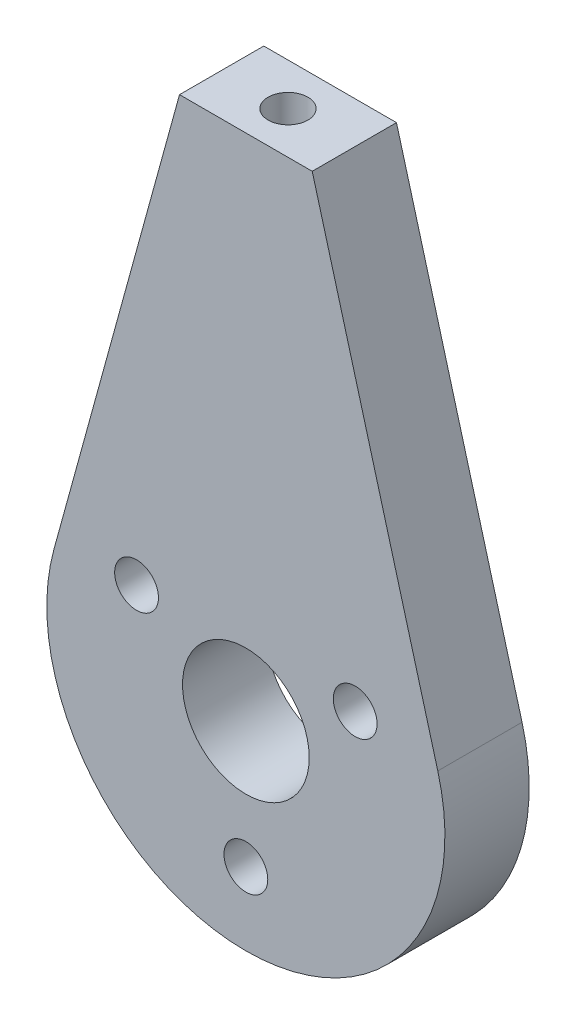
from build123d import *

# Parameters (mm, degrees)
BASE_DEPTH           = 3.175
BOSS_EXTRUDE1_DEPTH  = 6.35
SKETCH2_R            = 4.77266
SHAFT_AND_BOLT_DEPTH = 7.35
SKETCH5_R            = 1.5
CUT_EXTRUDE1_DEPTH   = 14
SKETCH6_R            = 1.65
CUT_EXTRUDE2_DEPTH   = 7.35


with BuildPart() as part:
    # Sketch1 → Base (new body, symmetric)
    with BuildSketch(Plane.XY):
        with BuildLine():
            Line((-5, 38.38), (-14.46282813, 3.978266268))
            ThreePointArc((-14.46282813, 3.978266268), (-14.389347628, -4.236351595), (-10, -11.180339887))
            Line((-10, -11.180339887), (10, -11.180339887))
            ThreePointArc((10, -11.180339887), (14.389347628, -4.236351595), (14.46282813, 3.978266268))
            Line((14.46282813, 3.978266268), (5, 38.38))
            Line((5, 38.38), (-5, 38.38))
        make_face()
    extrude(amount=BASE_DEPTH, both=True)

    # Sketch7 → Boss-Extrude1 (add)
    with BuildSketch(Plane.XY.offset(3.175)):
        with BuildLine():
            Line((-10, -11.180339887), (10, -11.180339887))
            ThreePointArc((10, -11.180339887), (0, -15), (-10, -11.180339887))
        make_face()
    extrude(amount=-BOSS_EXTRUDE1_DEPTH)

    # Sketch2 → Shaft and Bolt (cut, through all)
    with BuildSketch(Plane.XY.offset(3.175)):
        Circle(SKETCH2_R)
    extrude(amount=-SHAFT_AND_BOLT_DEPTH, mode=Mode.SUBTRACT)

    # Sketch5 → Cut-Extrude1 (cut)
    with BuildSketch(Plane(origin=(0, 38.38, 0), x_dir=(1, 0, 0), z_dir=(0, 1, 0))):
        Circle(SKETCH5_R)
    extrude(amount=-CUT_EXTRUDE1_DEPTH, mode=Mode.SUBTRACT)

    # Sketch6 → Cut-Extrude2 (cut, through all)
    with BuildSketch(Plane.XY.offset(3.175)):
        with Locations((0, -9.5125)):
            Circle(SKETCH6_R)
        with Locations((-8.238066653, 4.75625)):
            Circle(SKETCH6_R)
        with Locations((8.238066653, 4.75625)):
            Circle(SKETCH6_R)
    extrude(amount=-CUT_EXTRUDE2_DEPTH, mode=Mode.SUBTRACT)


solid = part.part
